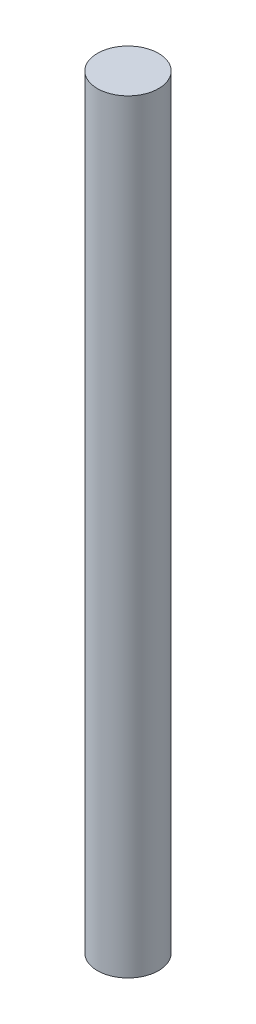
from build123d import *

# Parameters (mm, degrees)
SKETCH1_R           = 5
BOSS_EXTRUDE1_DEPTH = 125


with BuildPart() as part:
    # Sketch1 → Boss-Extrude1 (new body)
    with BuildSketch(Plane(origin=(0, 0, 0), x_dir=(1, 0, 0), z_dir=(0, 1, 0))):
        Circle(SKETCH1_R)
    extrude(amount=BOSS_EXTRUDE1_DEPTH)


solid = part.part
